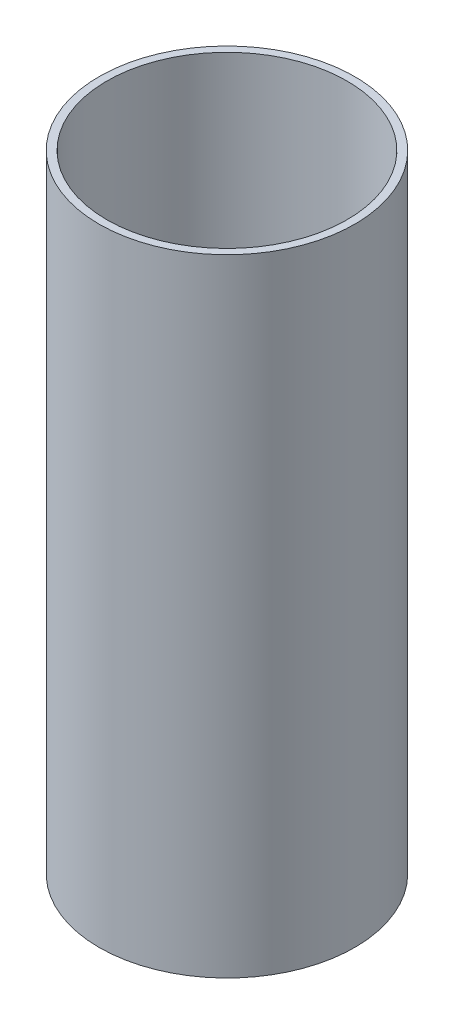
from build123d import *

# Parameters (mm, degrees)
SKETCH1_R           = 50
SKETCH1_R_2         = 47
BOSS_EXTRUDE1_DEPTH = 245


with BuildPart() as part:
    # Sketch1 → Boss-Extrude1 (new body)
    with BuildSketch(Plane(origin=(0, 0, 0), x_dir=(1, 0, 0), z_dir=(0, 1, 0))):
        Circle(SKETCH1_R)
        Circle(SKETCH1_R_2, mode=Mode.SUBTRACT)
    extrude(amount=BOSS_EXTRUDE1_DEPTH)


solid = part.part
